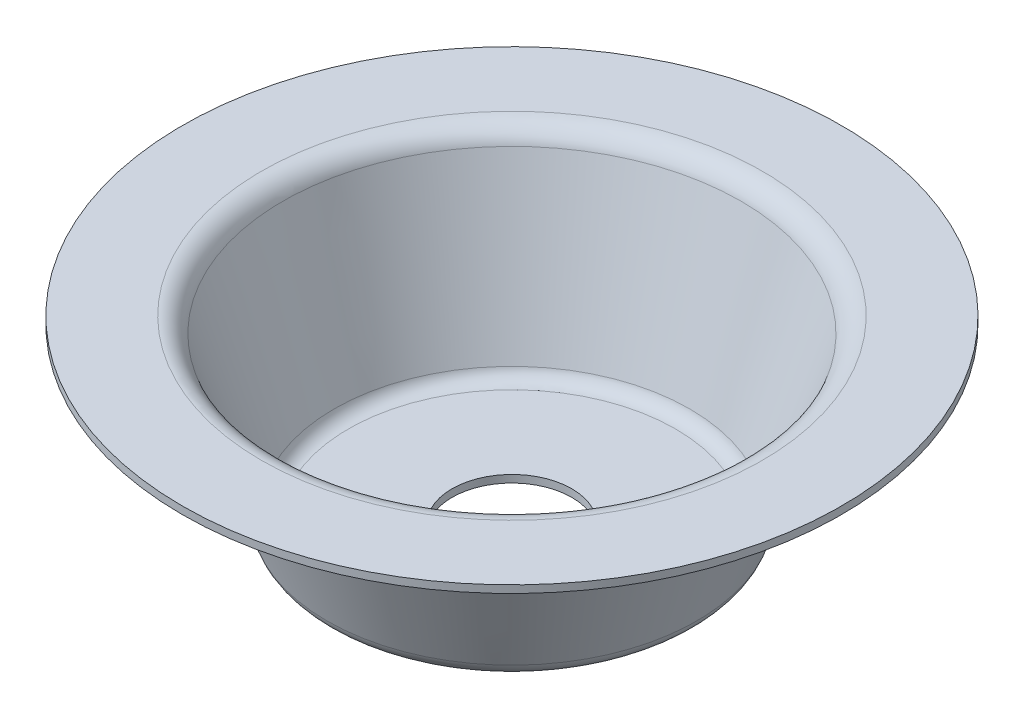
from build123d import *

# Parameters (mm, degrees)
SKETCH2_R          = 12.7
CUT_EXTRUDE1_DEPTH = 40.6875


with BuildPart() as part:
    # Sketch1 → Revolve-Thin1 (revolve)
    with BuildSketch(Plane.XY):
        with BuildLine():
            Line((0, 0), (-34.667384214, 0))
            ThreePointArc((-34.667384214, 0), (-37.452066945, 0.898959093), (-39.185488421, 3.256465264))
            Line((-39.185488421, 3.256465264), (-50.076341052, 35.929023157))
            ThreePointArc((-50.076341052, 35.929023157), (-51.23195537, 37.500693938), (-53.088410524, 38.1))
            Line((-53.088410524, 38.1), (-69.85, 38.1))
            Line((-69.85, 38.1), (-69.85, 39.6875))
            Line((-69.85, 39.6875), (-53.088410524, 39.6875))
            ThreePointArc((-53.088410524, 39.6875), (-50.303727793, 38.788540907), (-48.570306317, 36.431034736))
            Line((-48.570306317, 36.431034736), (-37.679453686, 3.758476843))
            ThreePointArc((-37.679453686, 3.758476843), (-36.523839368, 2.186806062), (-34.667384214, 1.5875))
            Line((-34.667384214, 1.5875), (0, 1.5875))
            Line((0, 1.5875), (0, 0))
        make_face()
    revolve(axis=Axis((0, 40.501267427, 0), (0, -1, 0)))

    # Sketch2 → Cut-Extrude1 (cut, through all)
    with BuildSketch(Plane.XZ):
        Circle(SKETCH2_R)
    extrude(amount=-CUT_EXTRUDE1_DEPTH, mode=Mode.SUBTRACT)


solid = part.part
